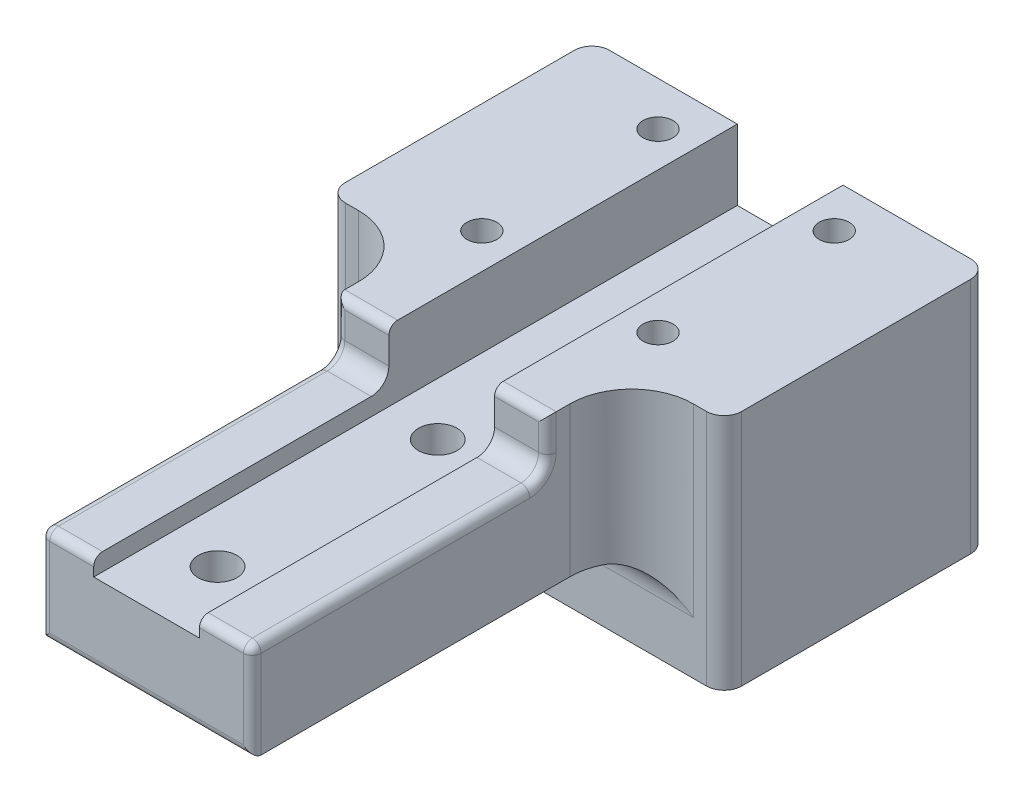
from build123d import *

# Parameters (mm, degrees)
SKETCH1_W           = 45
SKETCH1_H           = 30
SKETCH1_R           = 1.7
SKETCH1_W_2         = 24
SKETCH1_H_2         = 43.058371989
SKETCH1_R_2         = 2.2
BOSS_EXTRUDE2_DEPTH = 17
SKETCH5_W           = 12
SKETCH5_H           = 100
CUT_EXTRUDE1_DEPTH  = 8
SKETCH7_W           = 29.697028674
SKETCH7_H           = 34.988499238
CUT_EXTRUDE2_DEPTH  = 7
SKETCH9_W           = 45
SKETCH9_H           = 30
BOSS_EXTRUDE3_DEPTH = 10
FILLET1_R           = 7
FILLET6_R           = 2
FILLET7_R           = 1
FILLET8_R           = 4


with BuildPart() as part:
    # Sketch1 → Boss-Extrude2 (new body)
    with BuildSketch(Plane(origin=(0, 0, 0), x_dir=(1, 0, 0), z_dir=(0, 1, 0))):
        Rectangle(SKETCH1_W, SKETCH1_H)
        with Locations((-10, 10)):
            Circle(SKETCH1_R, mode=Mode.SUBTRACT)
        with Locations((10, 10)):
            Circle(SKETCH1_R, mode=Mode.SUBTRACT)
        with Locations((10, -10)):
            Circle(SKETCH1_R, mode=Mode.SUBTRACT)
        with Locations((-10, -10)):
            Circle(SKETCH1_R, mode=Mode.SUBTRACT)
        with Locations((0, -36.529185995)):
            Rectangle(SKETCH1_W_2, SKETCH1_H_2)
        with Locations((0, -25)):
            Circle(SKETCH1_R_2, mode=Mode.SUBTRACT)
        with Locations((0, -50)):
            Circle(SKETCH1_R_2, mode=Mode.SUBTRACT)
    extrude(amount=-BOSS_EXTRUDE2_DEPTH)

    # Sketch5 → Cut-Extrude1 (cut)
    with BuildSketch(Plane(origin=(0, 0, 0), x_dir=(1, 0, 0), z_dir=(0, 1, 0))):
        with Locations((0, -16.465194583)):
            Rectangle(SKETCH5_W, SKETCH5_H)
    extrude(amount=-CUT_EXTRUDE1_DEPTH, mode=Mode.SUBTRACT)

    # Sketch7 → Cut-Extrude2 (cut, through all)
    with BuildSketch(Plane(origin=(0, -6, 0), x_dir=(1, 0, 0), z_dir=(0, 1, 0))):
        with Locations((-0.809918964, -42.047133079)):
            Rectangle(SKETCH7_W, SKETCH7_H)
    extrude(amount=CUT_EXTRUDE2_DEPTH, mode=Mode.SUBTRACT)

    # Sketch9 → Boss-Extrude3 (add)
    with BuildSketch(Plane.XZ.offset(17)):
        Rectangle(SKETCH9_W, SKETCH9_H)
    extrude(amount=BOSS_EXTRUDE3_DEPTH)

    # Fillet1
    fillet1_edges = [part.edges().sort_by_distance(p)[0] for p in [
        (-12, -8.5, 15),
        (12, -8.5, 15),
    ]]
    fillet(fillet1_edges, radius=FILLET1_R)

    # Fillet6
    fillet6_edges = [part.edges().sort_by_distance(p)[0] for p in [
        (22.5, -13.5, 15),
        (-22.5, -13.5, 15),
        (-22.5, -13.5, -15),
        (22.5, -13.5, -15),
        (9, -6, 24.55288346),
        (-9, -6, 24.55288346),
    ]]
    fillet(fillet6_edges, radius=FILLET6_R)

    # Fillet7
    fillet7_edges = [part.edges().sort_by_distance(p)[0] for p in [
        (-12, -2, 24.55288346),
        (12, -2, 24.55288346),
        (-12, -5.414213562, 25.138669897),
        (12, -5.414213562, 25.138669897),
        (-12, -11.5, 58.058371989),
        (12, -11.5, 58.058371989),
        (0, -17, 58.058371989),
        (9, 0, 24.55288346),
        (9, -6, 58.058371989),
        (12, -6, 42.305627724),
        (-9, 0, 24.55288346),
        (-9, -6, 58.058371989),
        (-12, -6, 42.305627724),
    ]]
    fillet(fillet7_edges, radius=FILLET7_R)

    # Fillet8
    fillet8_edges = [part.edges().sort_by_distance(p)[0] for p in [
        (0, -17, 15),
    ]]
    fillet(fillet8_edges, radius=FILLET8_R)


solid = part.part
